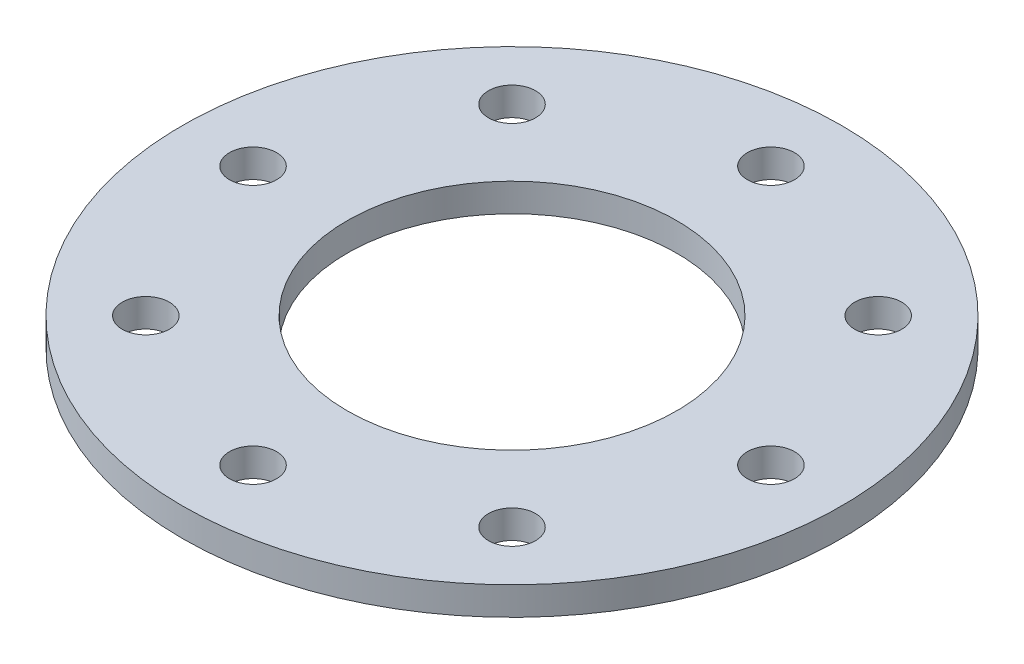
from build123d import *

# Parameters (mm, degrees)
SKETCH1_R             = 14
SKETCH1_R_2           = 7
BOSS_EXTRUDE1_DEPTH   = 0.6
F_2_0MM_DOWEL_HOLE1_D = 2
CIRPATTERN1_COUNT     = 8


with BuildPart() as part:
    # Sketch1 → Boss-Extrude1 (new body, symmetric)
    with BuildSketch(Plane(origin=(0, 0, 0), x_dir=(1, 0, 0), z_dir=(0, 1, 0))):
        Circle(SKETCH1_R)
        Circle(SKETCH1_R_2, mode=Mode.SUBTRACT)
    extrude(amount=BOSS_EXTRUDE1_DEPTH, both=True)

    # Ø2.0mm Dowel Hole1 (through all)
    with Locations(Plane(origin=(0, 0.6, 0), x_dir=(1, 0, 0), z_dir=(0, 1, 0))):
        with Locations((0, 11)):
            f_2_0mm_dowel_hole1 = Hole(F_2_0MM_DOWEL_HOLE1_D / 2)

    # CirPattern1: Ø2.0mm Dowel Hole1 ×8 about axis
    cirpattern1_axis = Axis((0, 0, 0), (0, 1, 0))
    for i in range(1, CIRPATTERN1_COUNT):
        add(f_2_0mm_dowel_hole1.rotate(cirpattern1_axis, i * 360 / CIRPATTERN1_COUNT), mode=Mode.SUBTRACT)


solid = part.part
